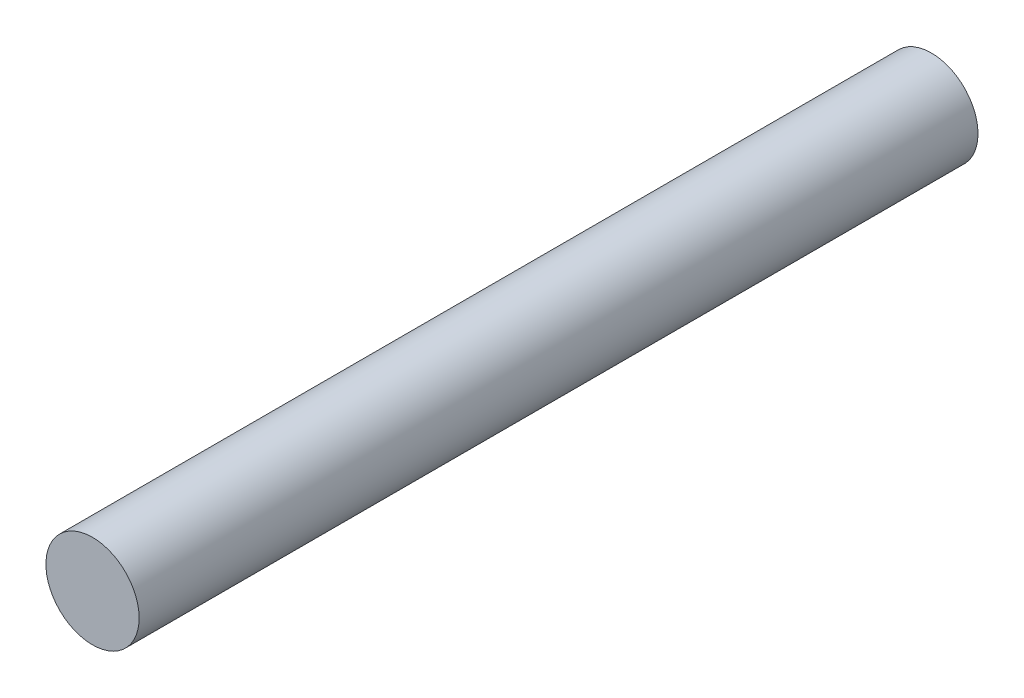
from build123d import *

# Parameters (mm, degrees)
SCHIZZO1_R                   = 2.5
ESTRUSIONE_ESTRUSIONE1_DEPTH = 45


with BuildPart() as part:
    # Schizzo1 → Estrusione-Estrusione1 (new body)
    with BuildSketch(Plane.XY):
        Circle(SCHIZZO1_R)
    extrude(amount=ESTRUSIONE_ESTRUSIONE1_DEPTH)


solid = part.part
